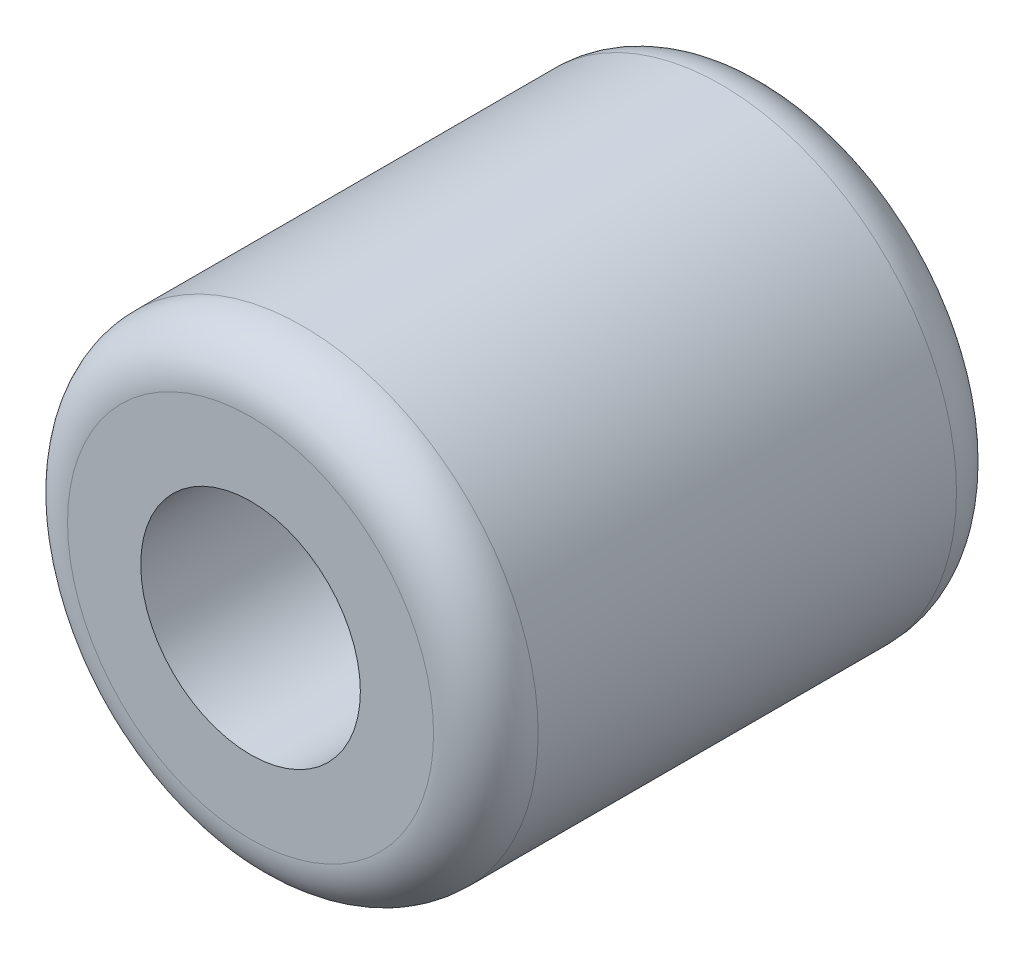
from build123d import *

# Parameters (mm, degrees)
SKIZZE1_R                       = 4.5
SKIZZE1_R_2                     = 2.1
AUFSATZ_LINEAR_AUSTRAGEN1_DEPTH = 10
VERRUNDUNG1_R                   = 1


with BuildPart() as part:
    # Skizze1 → Aufsatz-Linear austragen1 (new body)
    with BuildSketch(Plane.XY):
        Circle(SKIZZE1_R)
        Circle(SKIZZE1_R_2, mode=Mode.SUBTRACT)
    extrude(amount=AUFSATZ_LINEAR_AUSTRAGEN1_DEPTH)

    # Verrundung1
    verrundung1_edges = [part.edges().sort_by_distance(p)[0] for p in [
        (-4.5, 0, 0),
        (-4.5, 0, 10),
    ]]
    fillet(verrundung1_edges, radius=VERRUNDUNG1_R)


solid = part.part
